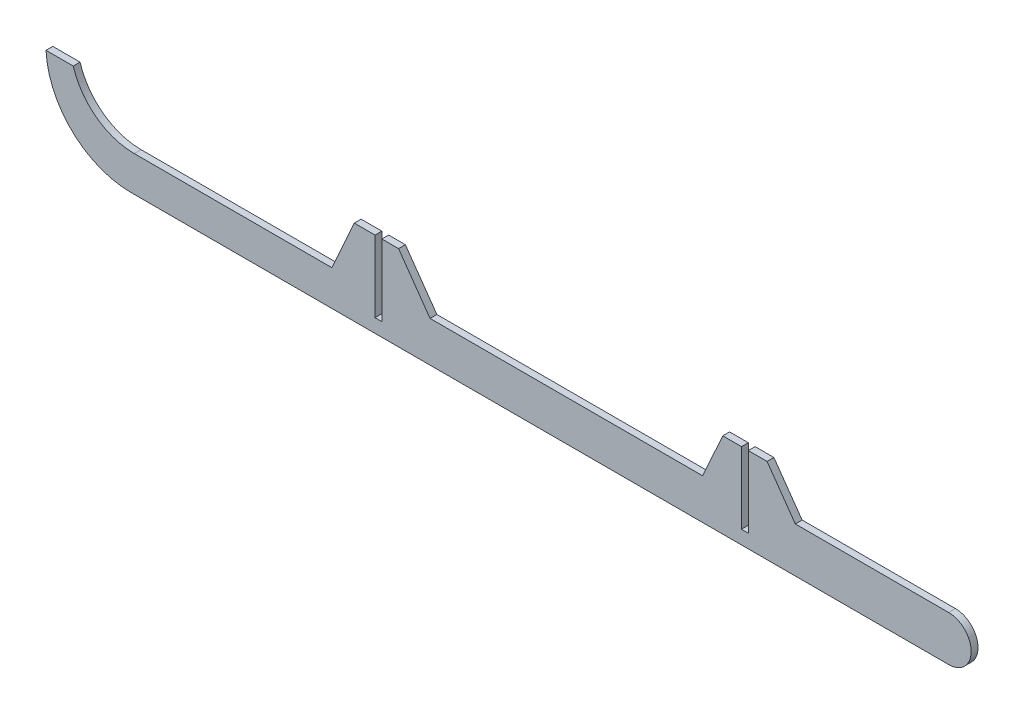
from build123d import *

# Parameters (mm, degrees)
RESSALTO_EXTRUS_O1_DEPTH = 2


with BuildPart() as part:
    # Esboço1 → Ressalto-extrusão1 (new body)
    with BuildSketch(Plane.XY):
        with BuildLine():
            Line((78.907701248, 0), (-161.092298752, 0))
            ThreePointArc((-161.092298752, 0), (-178.278212695, 6.861020331), (-186.013965864, 23.671355275))
            Line((-186.013965864, 23.671355275), (-178.013965864, 23.671355275))
            ThreePointArc((-178.013965864, 23.671355275), (-171.273030794, 14.060352601), (-160.128605048, 10.370724866))
            Line((-160.128605048, 10.370724866), (-102.128605048, 10.370724866))
            Line((-102.128605048, 10.370724866), (-95.535452379, 25))
            Line((-95.535452379, 25), (-89.442008497, 25))
            Line((-89.442008497, 25), (-89.442008497, 4))
            Line((-89.442008497, 4), (-87.442008497, 4))
            Line((-87.442008497, 4), (-87.442008497, 25))
            Line((-87.442008497, 25), (-82.535452379, 25))
            Line((-82.535452379, 25), (-73.291416334, 11.883859156))
            Line((-73.291416334, 11.883859156), (6.708583666, 11.883859156))
            Line((6.708583666, 11.883859156), (12.619793773, 25))
            Line((12.619793773, 25), (18.119793773, 25))
            Line((18.119793773, 25), (18.119793773, 4))
            Line((18.119793773, 4), (20.119793773, 4))
            Line((20.119793773, 4), (20.119793773, 25))
            Line((20.119793773, 25), (25.619793773, 25))
            Line((25.619793773, 25), (33.907701248, 13.240487032))
            Line((33.907701248, 13.240487032), (78.907701248, 13.240487032))
            ThreePointArc((78.907701248, 13.240487032), (85.527944764, 6.620243516), (78.907701248, 0))
        make_face()
    extrude(amount=RESSALTO_EXTRUS_O1_DEPTH)


solid = part.part
